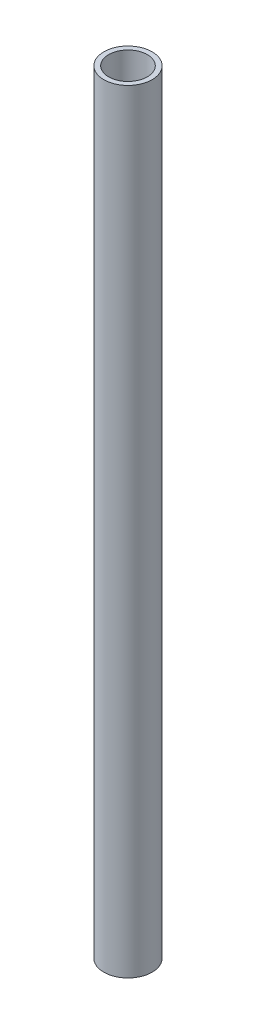
from build123d import *

# Parameters (mm, degrees)
SKETCH1_R           = 4.7625
SKETCH1_R_2         = 3.81
BOSS_EXTRUDE1_DEPTH = 152.4


with BuildPart() as part:
    # Sketch1 → Boss-Extrude1 (new body)
    with BuildSketch(Plane(origin=(0, 0, 0), x_dir=(1, 0, 0), z_dir=(0, 1, 0))):
        Circle(SKETCH1_R)
        Circle(SKETCH1_R_2, mode=Mode.SUBTRACT)
    extrude(amount=BOSS_EXTRUDE1_DEPTH)


solid = part.part
